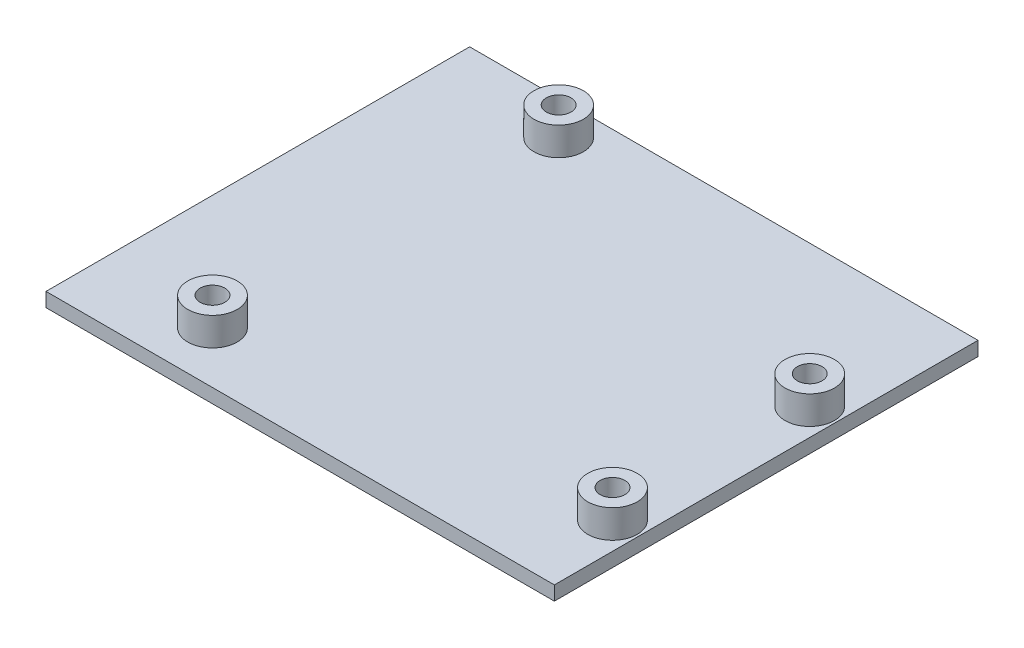
from build123d import *

# Parameters (mm, degrees)
ESQUISSE1_W             = 72
ESQUISSE1_H             = 60
BOSS_EXTRU_1_DEPTH      = 2
ESQUISSE3_R             = 3.5
BOSS_EXTRU_2_DEPTH      = 4
ESQUISSE2_R             = 1.75
ENL_V_MAT_EXTRU_1_DEPTH = 4


with BuildPart() as part:
    # Esquisse1 → Boss.-Extru.1 (new body)
    with BuildSketch(Plane(origin=(0, 0, 0), x_dir=(1, 0, 0), z_dir=(0, 1, 0))):
        Rectangle(ESQUISSE1_W, ESQUISSE1_H)
    extrude(amount=BOSS_EXTRU_1_DEPTH)

    # Esquisse3 → Boss.-Extru.2 (add)
    with BuildSketch(Plane(origin=(0, 2, 0), x_dir=(1, 0, 0), z_dir=(0, 1, 0))):
        with Locations((-19.741989578, -22.677254534)):
            Circle(ESQUISSE3_R)
        with Locations((32.17700457, -17.941217791)):
            Circle(ESQUISSE3_R)
        with Locations((32.180787909, 9.986620664)):
            Circle(ESQUISSE3_R)
        with Locations((-18.564843267, 25.173313711)):
            Circle(ESQUISSE3_R)
    extrude(amount=BOSS_EXTRU_2_DEPTH)

    # Esquisse2 → Enlèv. mat.-Extru.1 (cut)
    with BuildSketch(Plane(origin=(0, 2, 0), x_dir=(1, 0, 0), z_dir=(0, 1, 0))):
        with Locations((-18.564843267, 25.173313711)):
            Circle(ESQUISSE2_R)
        with Locations((32.180787909, 9.986620664)):
            Circle(ESQUISSE2_R)
        with Locations((32.17700457, -17.941217791)):
            Circle(ESQUISSE2_R)
        with Locations((-19.741989578, -22.677254534)):
            Circle(ESQUISSE2_R)
    extrude(amount=ENL_V_MAT_EXTRU_1_DEPTH, mode=Mode.SUBTRACT)


solid = part.part
